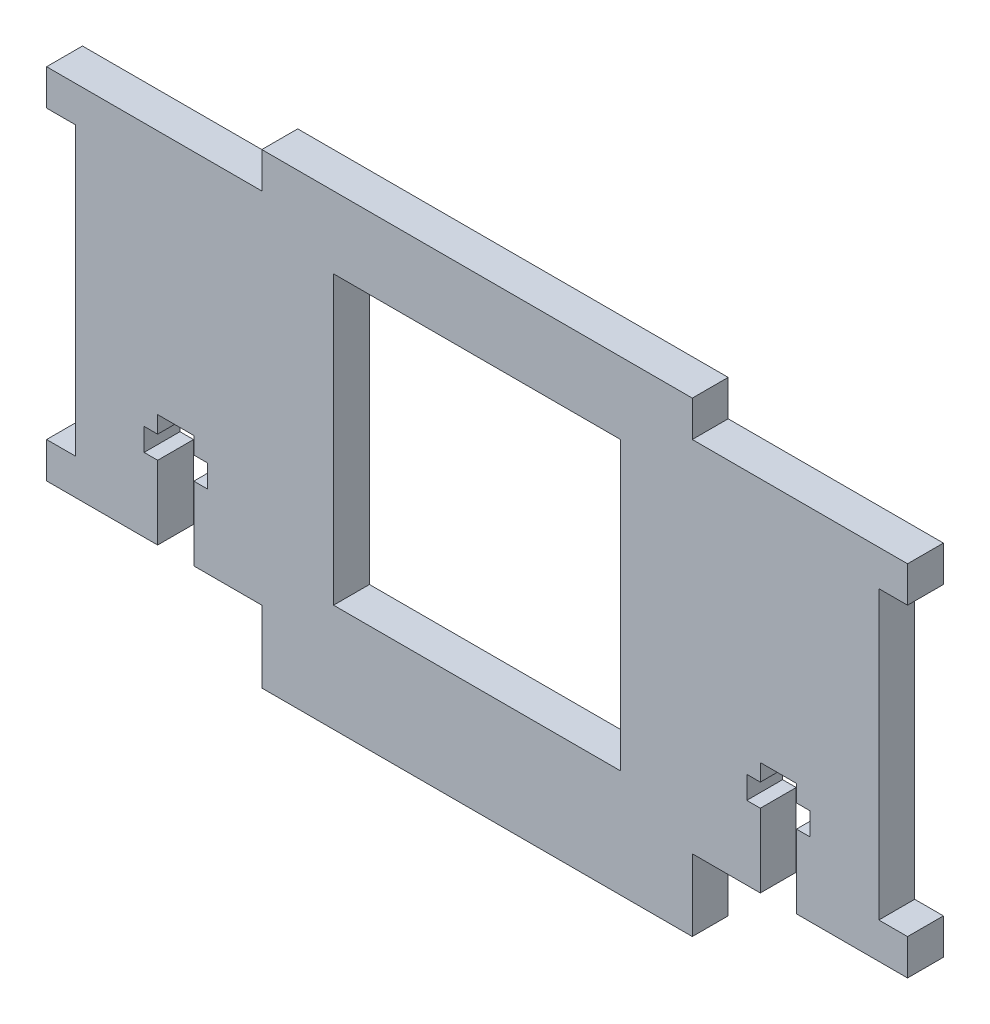
from build123d import *

# Parameters (mm, degrees)
SKETCH1_W           = 25.4
SKETCH1_H           = 25.4
BOSS_EXTRUDE1_DEPTH = 3.175
CUT_EXTRUDE1_DEPTH  = 4.175


with BuildPart() as part:
    # Sketch1 → Boss-Extrude1 (new body)
    with BuildSketch(Plane.XY):
        Polygon((0, 0), (19.05, 0), (19.05, -6.35), (57.15, -6.35), (57.15, 0), (76.2, 0), (76.2, 3.175), (73.66, 3.175), (73.66, 28.575), (76.2, 28.575), (76.2, 31.75), (57.15, 31.75), (57.15, 34.925), (19.05, 34.925), (19.05, 31.75), (0, 31.75), (0, 28.575), (2.54, 28.575), (2.54, 3.175), (0, 3.175), align=None)
        with Locations((38.1, 15.875)):
            Rectangle(SKETCH1_W, SKETCH1_H, mode=Mode.SUBTRACT)
    extrude(amount=BOSS_EXTRUDE1_DEPTH)

    # Sketch2 → Cut-Extrude1 (cut, through all)
    with BuildSketch(Plane.XY.offset(3.175)):
        Polygon((13.03, 0), (9.83, 0), (9.83, 6.5), (8.63, 6.5), (8.63, 8.5), (9.83, 8.5), (9.83, 10), (13.03, 10), (13.03, 8.5), (14.23, 8.5), (14.23, 6.5), (13.03, 6.5), align=None)
        Polygon((66.37, 8.5), (66.37, 10), (63.17, 10), (63.17, 8.5), (61.97, 8.5), (61.97, 6.5), (63.17, 6.5), (63.17, 0), (66.37, 0), (66.37, 6.5), (67.57, 6.5), (67.57, 8.5), align=None)
    extrude(amount=-CUT_EXTRUDE1_DEPTH, mode=Mode.SUBTRACT)


solid = part.part
